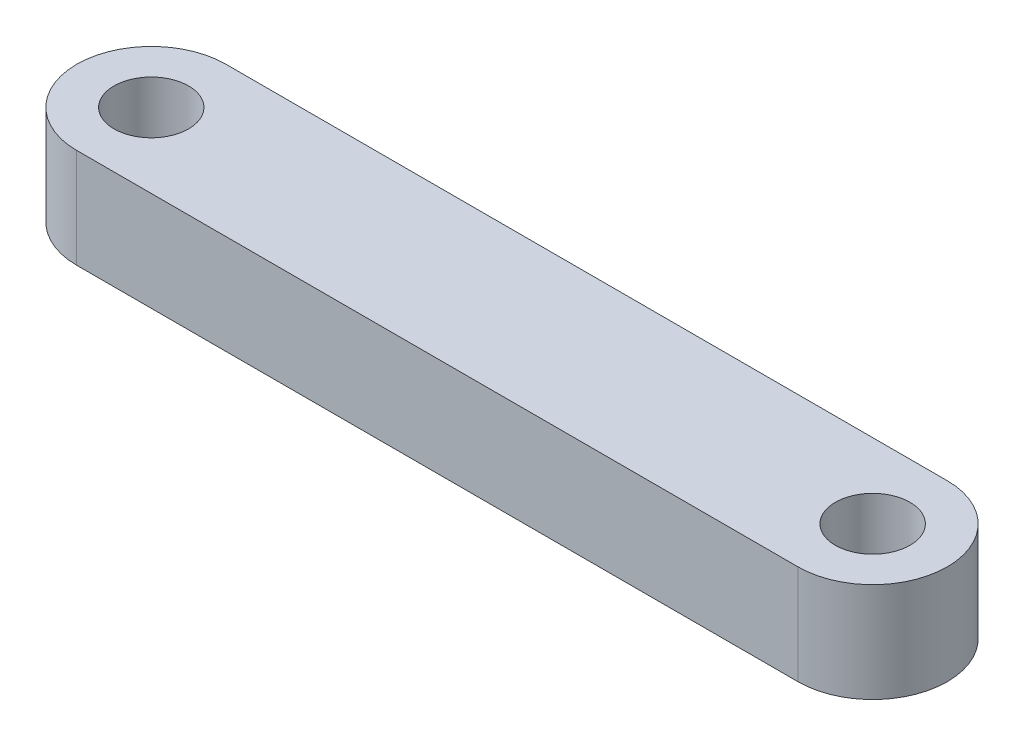
from build123d import *

# Parameters (mm, degrees)
CROQUIS1_R              = 1.500000151
CROQUIS1_R_2            = 1.498520087
SALIENTE_EXTRUIR1_DEPTH = 4


with BuildPart() as part:
    # Croquis1 → Saliente-Extruir1 (new body)
    with BuildSketch(Plane(origin=(0, 0, 0), x_dir=(1, 0, 0), z_dir=(0, 1, 0))):
        with BuildLine():
            Line((-14.995469687, 4.362520553), (14.00454042, 4.362520553))
            ThreePointArc((14.00454042, 4.362520553), (17.00453793, 1.362523043), (14.00454042, -1.637474466))
            Line((14.00454042, -1.637474466), (-14.995469687, -1.637474466))
            ThreePointArc((-14.995469687, -1.637474466), (-17.995467197, 1.362523043), (-14.995469687, 4.362520553))
        make_face()
        with Locations((14.004530353, 1.362523139)):
            Circle(CROQUIS1_R, mode=Mode.SUBTRACT)
        with Locations((-14.993677621, 1.35896826)):
            Circle(CROQUIS1_R_2, mode=Mode.SUBTRACT)
    extrude(amount=SALIENTE_EXTRUIR1_DEPTH)


solid = part.part
